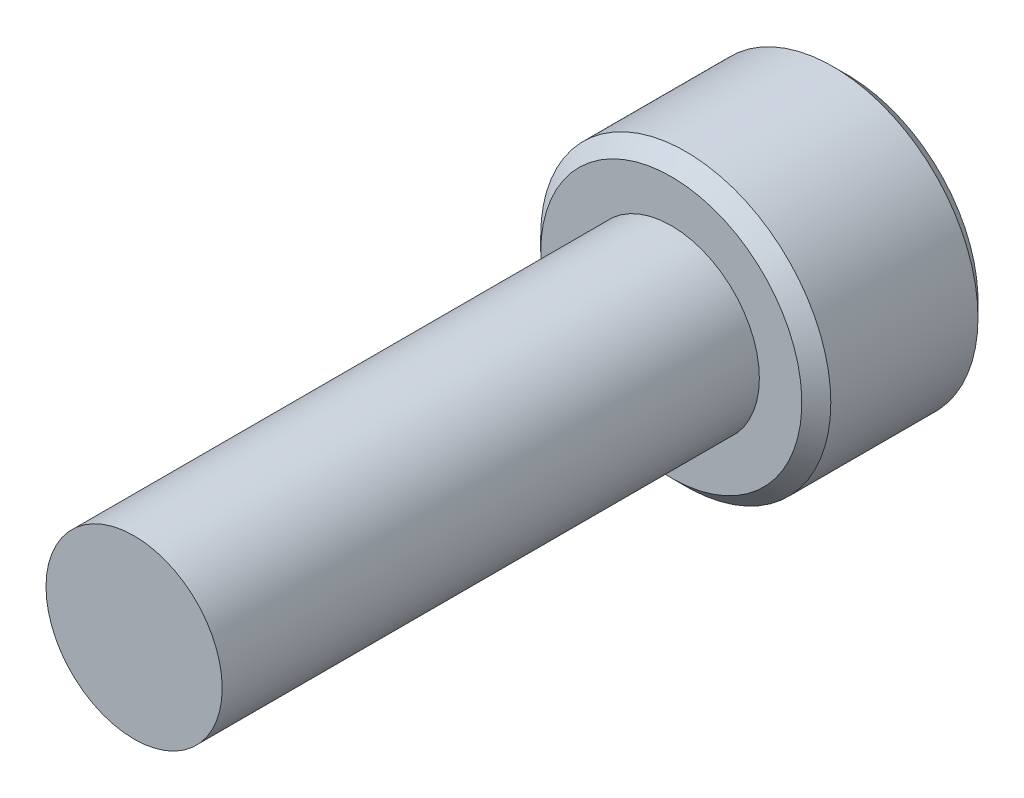
from build123d import *

# Parameters (mm, degrees)
SKETCH1_R          = 2.0828
EXTRUDE1_DEPTH     = 12.7
SKETCH6_R          = 3.429
EXTRUDE2_DEPTH     = 4.1656
CUT_EXTRUDE1_DEPTH = 2.67890625
CHAMFER1_SIZE      = 0.3429


with BuildPart() as part:
    # Sketch1 → Extrude1 (new body)
    with BuildSketch(Plane.XY):
        Circle(SKETCH1_R)
    extrude(amount=-EXTRUDE1_DEPTH)

    # Sketch6 → Extrude2 (add)
    with BuildSketch(Plane(origin=(0, 0, -12.7), x_dir=(-1, 0, 0), z_dir=(0, 0, -1))):
        Circle(SKETCH6_R)
    extrude(amount=EXTRUDE2_DEPTH)

    # Sketch7 → Cut-Extrude1 (cut)
    with BuildSketch(Plane(origin=(0, 0, -16.8656), x_dir=(-1, 0, 0), z_dir=(0, 0, -1))):
        Polygon((0, 2.062222993), (-1.7859375, 1.031111496), (-1.7859375, -1.031111496), (0, -2.062222993), (1.7859375, -1.031111496), (1.7859375, 1.031111496), align=None)
    extrude(amount=-CUT_EXTRUDE1_DEPTH, mode=Mode.SUBTRACT)

    # Cut-Extrude2 cone 1 section (through the dimple's axis) → Cut-Extrude2 (revolve, cut)
    with BuildSketch(Plane(origin=(0, 0, -16.8656), x_dir=(0, 1, 0), z_dir=(1, 0, 0))):
        Polygon((0, 0), (2.062222993, 0), (0, 2.062222993), align=None)
    revolve(axis=Axis((0, 0, -16.8656), (0, 0, 1)), mode=Mode.SUBTRACT)

    # Chamfer1
    chamfer1_edges = [part.edges().sort_by_distance(p)[0] for p in [
        (3.429, 0, -16.8656),
        (3.429, 0, -12.7),
    ]]
    chamfer(chamfer1_edges, length=CHAMFER1_SIZE)


solid = part.part
